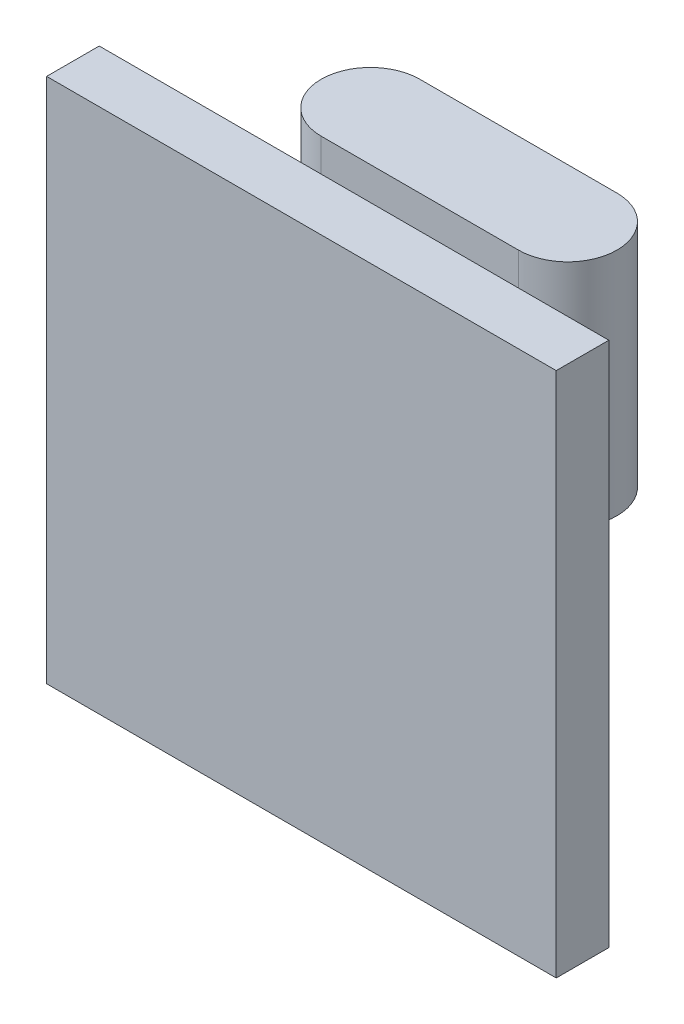
from build123d import *

# Parameters (mm, degrees)
ESBO_O1_W                     = 15.5
ESBO_O1_H                     = 16
RESSALTO_EXTRUS_O1_DEPTH      = 1.6
RESSALTO_EXTRUS_O2_DEPTH      = 1
RESSALTO_EXTRUS_O2_DEPTH_BACK = 6


with BuildPart() as part:
    # Esboço1 → Ressalto-extrusão1 (new body)
    with BuildSketch(Plane.XY):
        Rectangle(ESBO_O1_W, ESBO_O1_H)
    extrude(amount=RESSALTO_EXTRUS_O1_DEPTH)

    # Esboço3 → Ressalto-extrusão2 (add, two sides)
    with BuildSketch(Plane(origin=(0, 8, 0), x_dir=(1, 0, 0), z_dir=(0, 1, 0))) as ressalto_extrus_o2_sk:
        with BuildLine():
            Line((-1, 3), (5, 3))
            ThreePointArc((5, 3), (6.5, 1.5), (5, 0))
            Line((5, 0), (-1, 0))
            ThreePointArc((-1, 0), (-2.5, 1.5), (-1, 3))
        make_face()
    extrude(amount=RESSALTO_EXTRUS_O2_DEPTH)
    extrude(ressalto_extrus_o2_sk.sketch, amount=-RESSALTO_EXTRUS_O2_DEPTH_BACK)


solid = part.part
